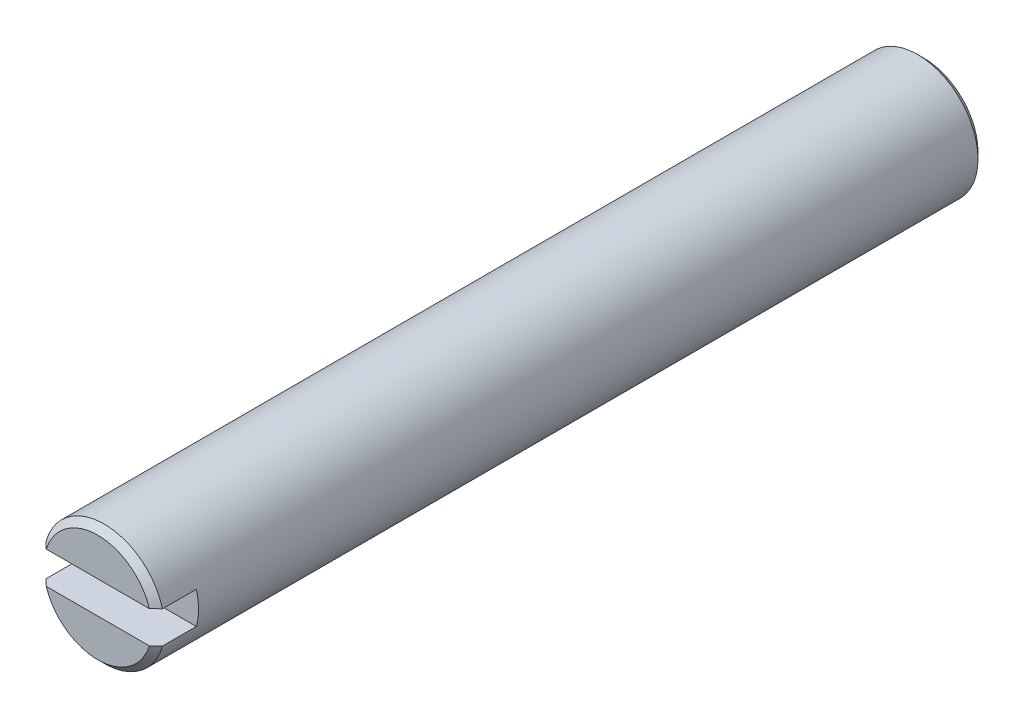
from build123d import *

# Parameters (mm, degrees)
SKETCH2_R           = 4.7625
BOSS_EXTRUDE1_DEPTH = 65.1002
CUT_EXTRUDE1_DEPTH  = 3.175
CHAMFER1_SIZE       = 0.508


with BuildPart() as part:
    # Sketch2 → Boss-Extrude1 (new body)
    with BuildSketch(Plane.XY):
        Circle(SKETCH2_R)
    extrude(amount=BOSS_EXTRUDE1_DEPTH)

    # Sketch3 → Cut-Extrude1 (cut)
    with BuildSketch(Plane.XY.offset(65.1002)):
        Polygon((4.7625, 0), (4.7625, 1.27), (-4.7625, 1.27), (-4.7625, 0), (-4.7625, -1.27), (4.7625, -1.27), align=None)
    extrude(amount=-CUT_EXTRUDE1_DEPTH, mode=Mode.SUBTRACT)

    # Chamfer1
    chamfer1_edges = [part.edges().sort_by_distance(p)[0] for p in [
        (-4.7625, 0, 0),
        (0, 4.7625, 65.1002),
        (0, -4.7625, 65.1002),
    ]]
    chamfer(chamfer1_edges, length=CHAMFER1_SIZE)


solid = part.part
